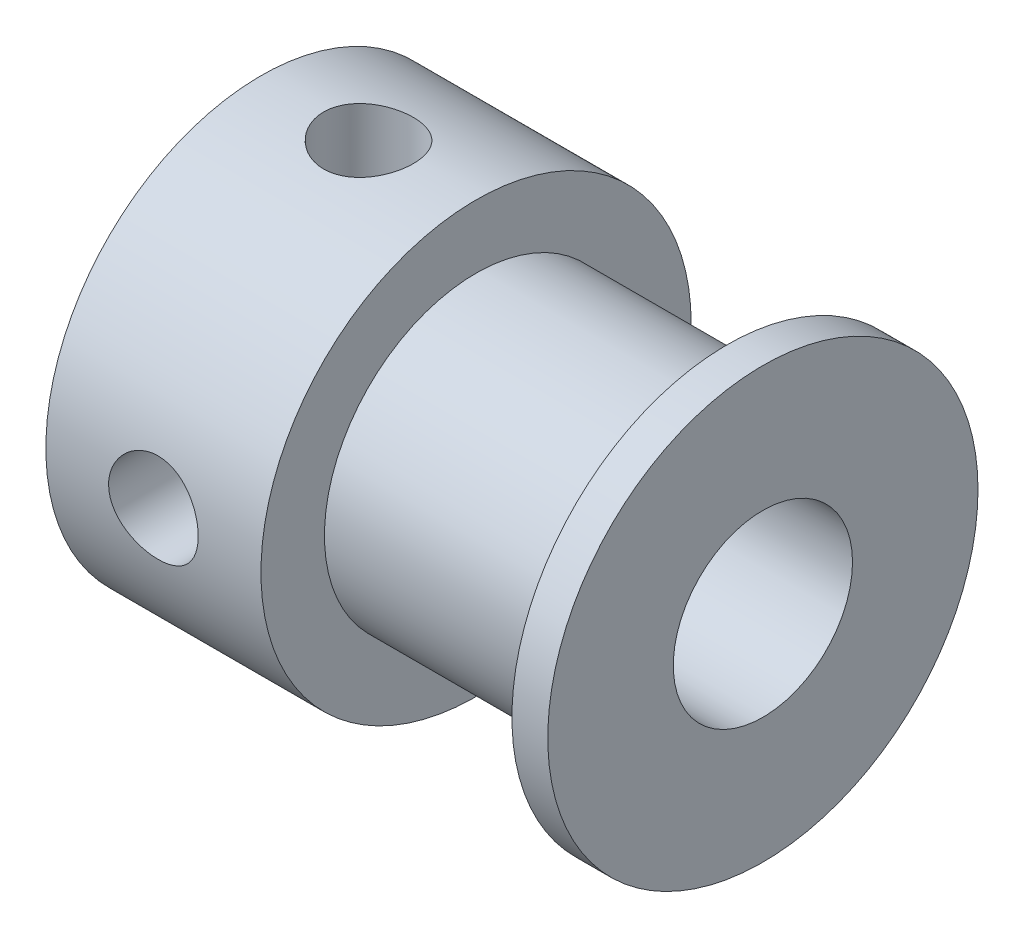
from build123d import *

# Parameters (mm, degrees)
SKETCH2_W = 1.25
SKETCH2_H = 6
SKETCH4_W = 1.25
SKETCH4_H = 6


with BuildPart() as part:
    # Sketch1 → Revolve1 (revolve)
    with BuildSketch(Plane.XY):
        Polygon((0, 2.5), (0, 6), (6, 6), (6, 4.2291), (13, 4.2291), (13, 6), (14, 6), (14, 2.5), align=None)
    revolve(axis=Axis((0, 0, 0), (-1, 0, 0)))

    # Sketch2 → M3x0.5 Tapped Hole1 (revolve, cut)
    with BuildSketch(Plane(origin=(3, 0, 0), x_dir=(0, 0, -1), z_dir=(1, 0, 0))):
        with Locations((0.625, 3)):
            Rectangle(SKETCH2_W, SKETCH2_H)
    revolve(axis=Axis((3, -6.35, 0), (0, 1, 0)), mode=Mode.SUBTRACT)

    # Sketch4 → M3x0.5 Tapped Hole2 (revolve, cut)
    with BuildSketch(Plane.YZ.offset(3)):
        with Locations((0.625, 3)):
            Rectangle(SKETCH4_W, SKETCH4_H)
    revolve(axis=Axis((3, 0, -6.35), (0, 0, 1)), mode=Mode.SUBTRACT)


solid = part.part
